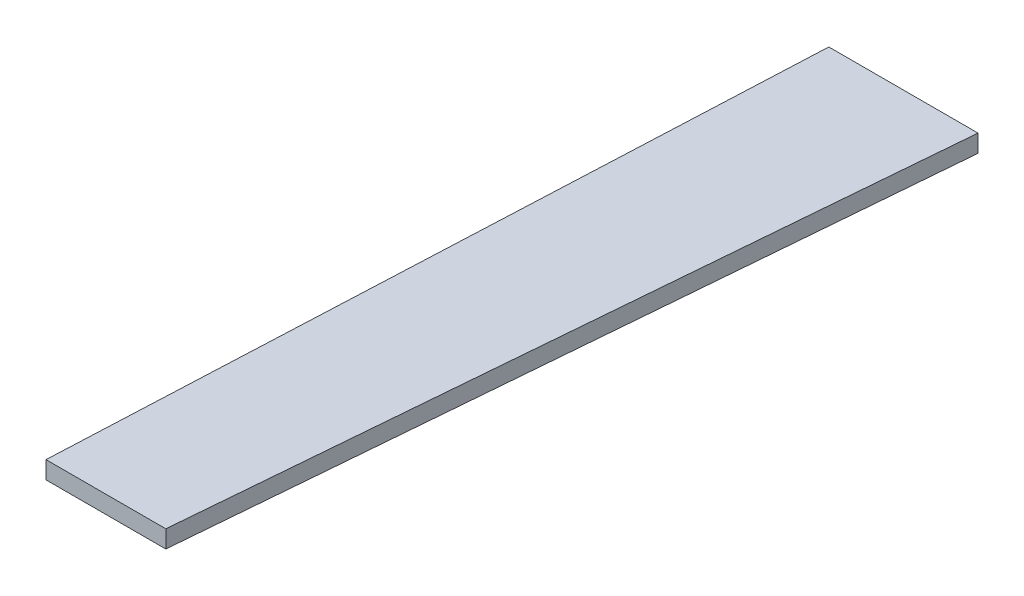
from build123d import *

# Parameters (mm, degrees)
BOSS_EXTRUDE1_DEPTH = 10


with BuildPart() as part:
    # Sketch1 → Boss-Extrude1 (new body)
    with BuildSketch(Plane(origin=(0, 0, 0), x_dir=(1, 0, 0), z_dir=(0, 1, 0))):
        Polygon((-19.395399332, -426.72), (48.871400668, -426.72), (85.009811287, 0), (0, 0), align=None)
    extrude(amount=BOSS_EXTRUDE1_DEPTH)


solid = part.part
